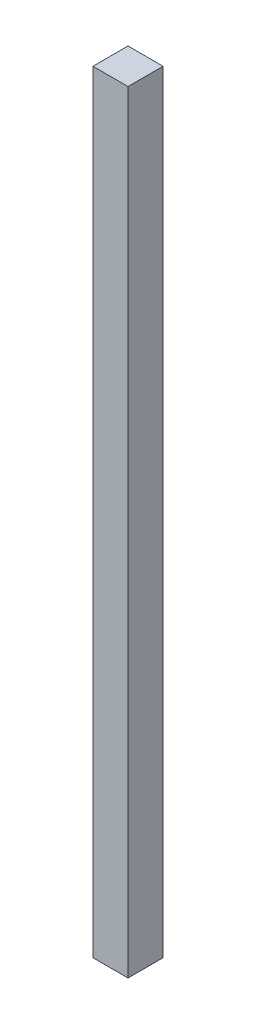
from build123d import *

# Parameters (mm, degrees)
SKETCH1_W           = 100
SKETCH1_H           = 100
BOSS_EXTRUDE1_DEPTH = 2200


with BuildPart() as part:
    # Sketch1 → Boss-Extrude1 (new body)
    with BuildSketch(Plane(origin=(0, 0, 0), x_dir=(1, 0, 0), z_dir=(0, 1, 0))):
        Rectangle(SKETCH1_W, SKETCH1_H)
    extrude(amount=BOSS_EXTRUDE1_DEPTH)


solid = part.part
